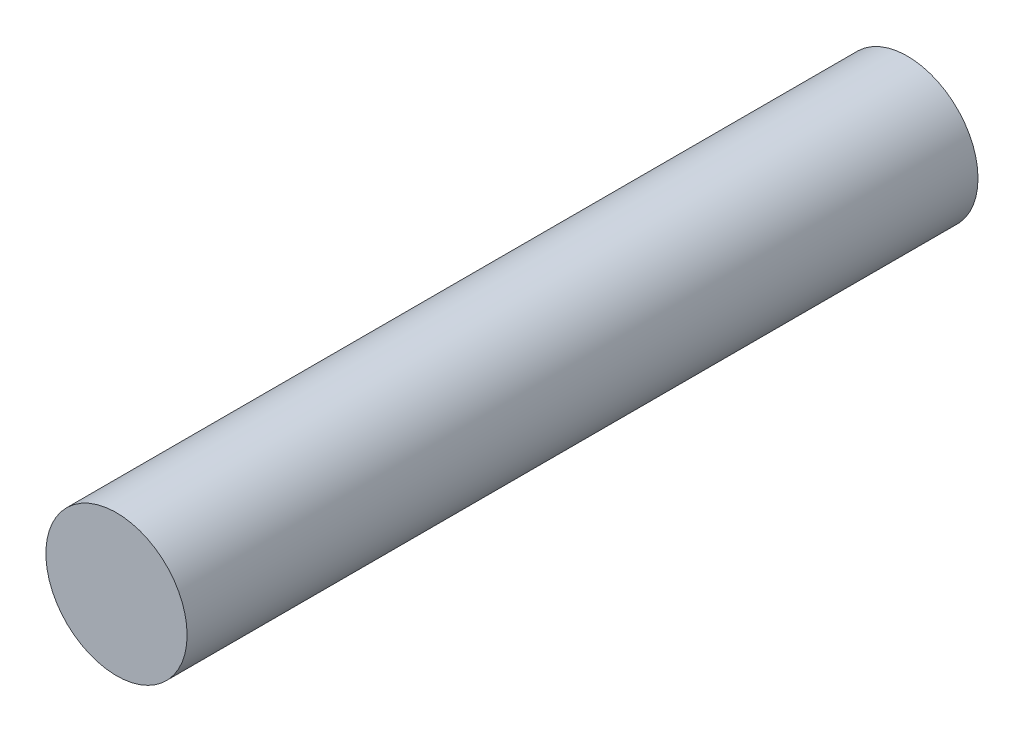
from build123d import *

# Parameters (mm, degrees)
CROQUIS6_R               = 2.5
SALIENTE_EXTRUIR12_DEPTH = 28
ESCALA1_SCALE            = 7


with BuildPart() as part:
    # Croquis6 → Saliente-Extruir12 (new body)
    with BuildSketch(Plane.XY):
        Circle(CROQUIS6_R)
    extrude(amount=SALIENTE_EXTRUIR12_DEPTH)


with BuildPart() as part_1:
    # Escala1: scaled about (0, 0, 14)
    add(part.part.scale(ESCALA1_SCALE).moved(Location((0, 0, -84))))


solid = part_1.part
